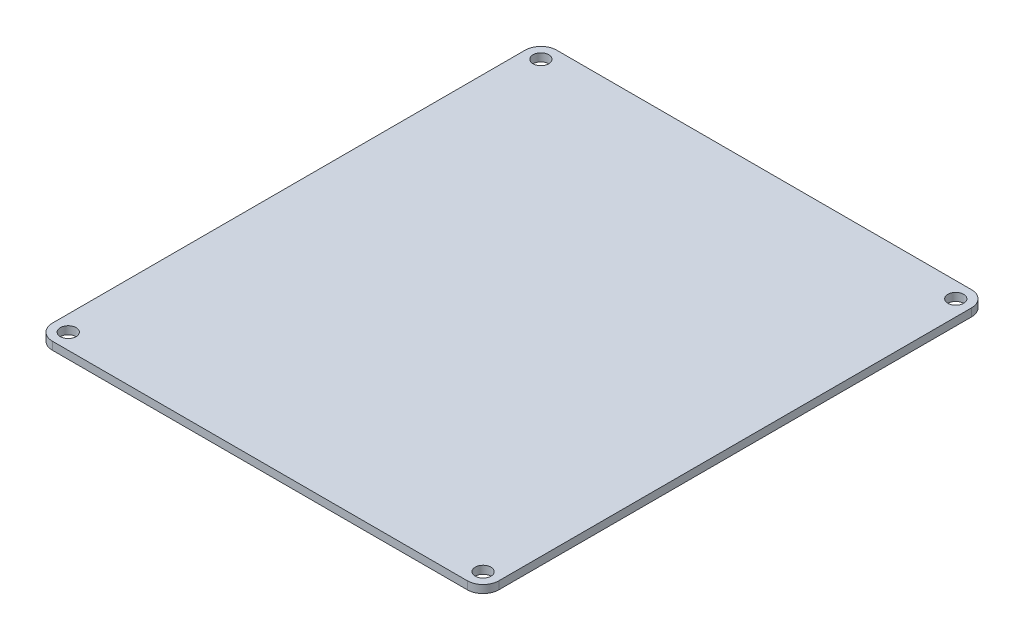
from build123d import *

# Parameters (mm, degrees)
SKETCH1_W           = 179.900000372
SKETCH1_H           = 203.2
SKETCH1_R           = 3.175
BOSS_EXTRUDE1_DEPTH = 3.175
FILLET1_R           = 6.35


with BuildPart() as part:
    # Sketch1 → Boss-Extrude1 (new body)
    with BuildSketch(Plane(origin=(0, 0, 0), x_dir=(1, 0, 0), z_dir=(0, 1, 0))):
        with Locations((57.15, 101.6)):
            Rectangle(SKETCH1_W, SKETCH1_H)
        with Locations((-26.450000186, 6.35)):
            Circle(SKETCH1_R, mode=Mode.SUBTRACT)
        with Locations((140.750000186, 6.35)):
            Circle(SKETCH1_R, mode=Mode.SUBTRACT)
        with Locations((-26.450000186, 196.85)):
            Circle(SKETCH1_R, mode=Mode.SUBTRACT)
        with Locations((140.750000186, 196.85)):
            Circle(SKETCH1_R, mode=Mode.SUBTRACT)
    extrude(amount=BOSS_EXTRUDE1_DEPTH)

    # Fillet1
    fillet1_edges = [part.edges().sort_by_distance(p)[0] for p in [
        (-32.800000186, 1.5875, -203.2),
        (147.100000186, 1.5875, -203.2),
        (147.100000186, 1.5875, 0),
        (-32.800000186, 1.5875, 0),
    ]]
    fillet(fillet1_edges, radius=FILLET1_R)


solid = part.part
